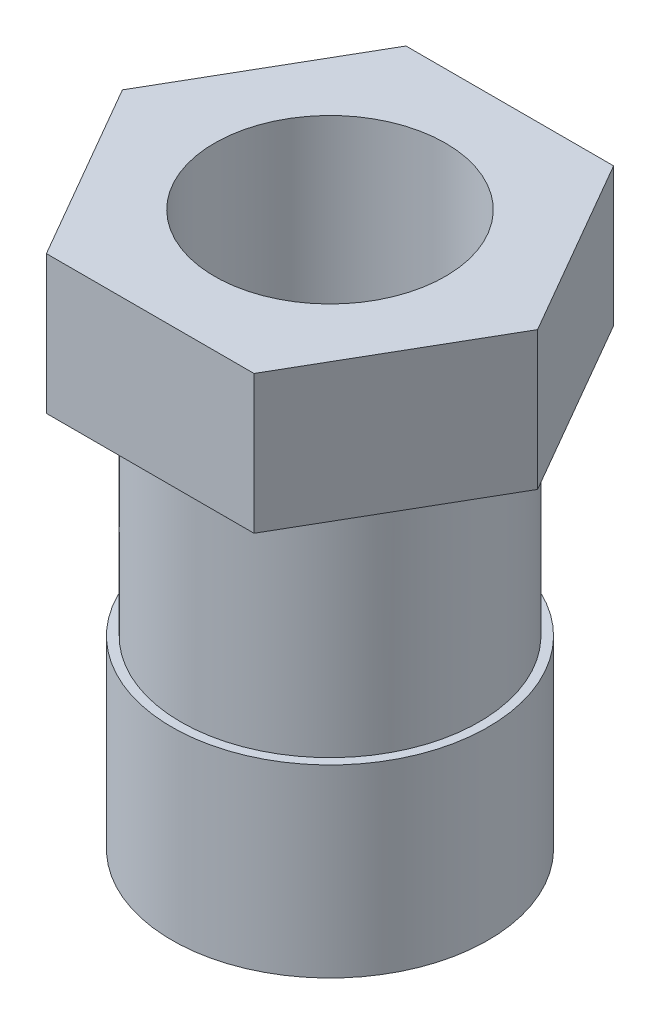
from build123d import *

# Parameters (mm, degrees)
SALIENTE_EXTRUIR1_DEPTH = 15
CROQUIS2_R              = 16.164040976
SALIENTE_EXTRUIR2_DEPTH = 25
CROQUIS3_R              = 17.134212929
SALIENTE_EXTRUIR3_DEPTH = 20
CROQUIS4_R              = 12.514075771
CORTAR_EXTRUIR1_DEPTH   = 61


with BuildPart() as part:
    # Croquis1 → Saliente-Extruir1 (new body)
    with BuildSketch(Plane(origin=(0, 0, 0), x_dir=(1, 0, 0), z_dir=(0, 1, 0))):
        Polygon((22.5, 0), (11.25, 19.485571585), (-11.25, 19.485571585), (-22.5, 0), (-11.25, -19.485571585), (11.25, -19.485571585), align=None)
    extrude(amount=SALIENTE_EXTRUIR1_DEPTH)

    # Croquis2 → Saliente-Extruir2 (add)
    with BuildSketch(Plane.XZ):
        Circle(CROQUIS2_R)
    extrude(amount=SALIENTE_EXTRUIR2_DEPTH)

    # Croquis3 → Saliente-Extruir3 (add)
    with BuildSketch(Plane.XZ.offset(25)):
        Circle(CROQUIS3_R)
    extrude(amount=SALIENTE_EXTRUIR3_DEPTH)

    # Croquis4 → Cortar-Extruir1 (cut, through all)
    with BuildSketch(Plane.XZ.offset(45)):
        Circle(CROQUIS4_R)
    extrude(amount=-CORTAR_EXTRUIR1_DEPTH, mode=Mode.SUBTRACT)


solid = part.part
